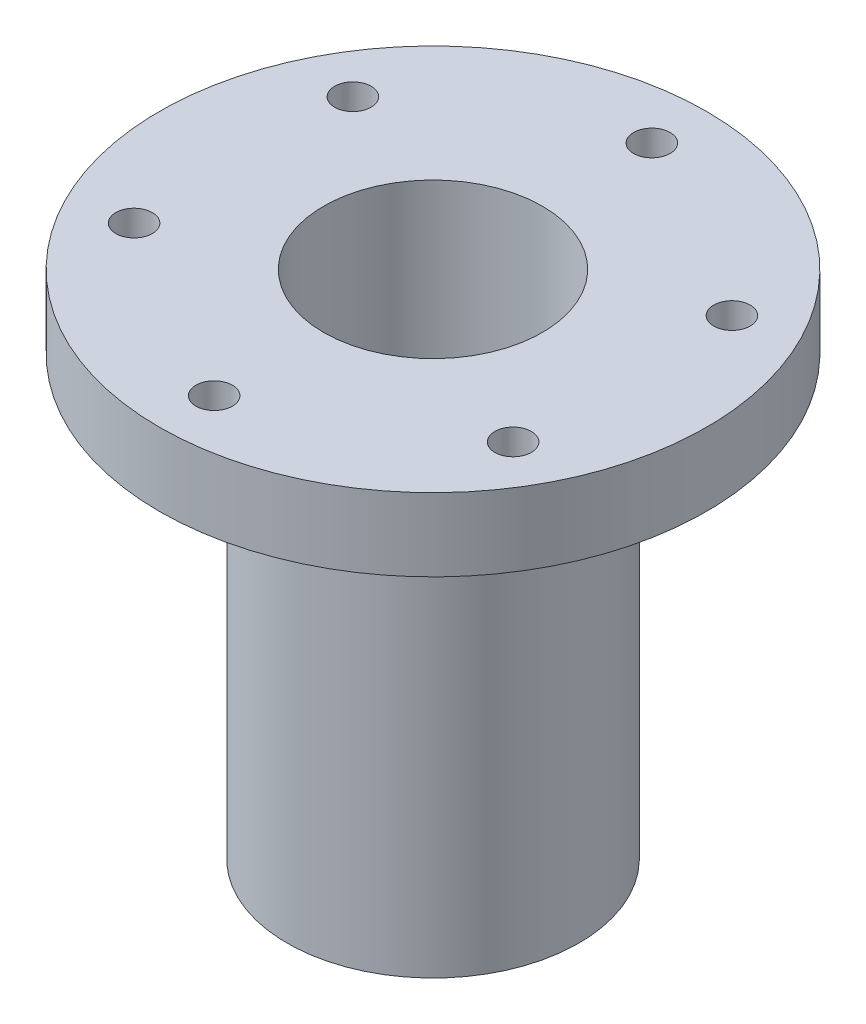
from build123d import *

# Parameters (mm, degrees)
F_1_8_0_125_DIAMETER_HOLE2_D = 3.175


with BuildPart() as part:
    # Sketch1 → Revolve1 (revolve)
    with BuildSketch(Plane.XY):
        Polygon((-9.525, -31.199666667), (-9.525, 13.250333333), (-23.8125, 13.250333333), (-23.8125, 6.900333333), (-12.7, 6.900333333), (-12.7, -31.199666667), align=None)
    revolve(axis=Axis((0, 0, 0), (0, 1, 0)))

    # 1/8 (0.125) Diameter Hole2 (through all)
    with Locations(Plane(origin=(0, 6.900333333, 0), x_dir=(-1, 0, 0), z_dir=(0, -1, 0))):
        with Locations((0, 19.05), (16.497783942, 9.525), (16.497783942, -9.525), (0, -19.05), (-16.497783942, -9.525), (-16.497783942, 9.525), (0, 0)):
            Hole(F_1_8_0_125_DIAMETER_HOLE2_D / 2)


solid = part.part
